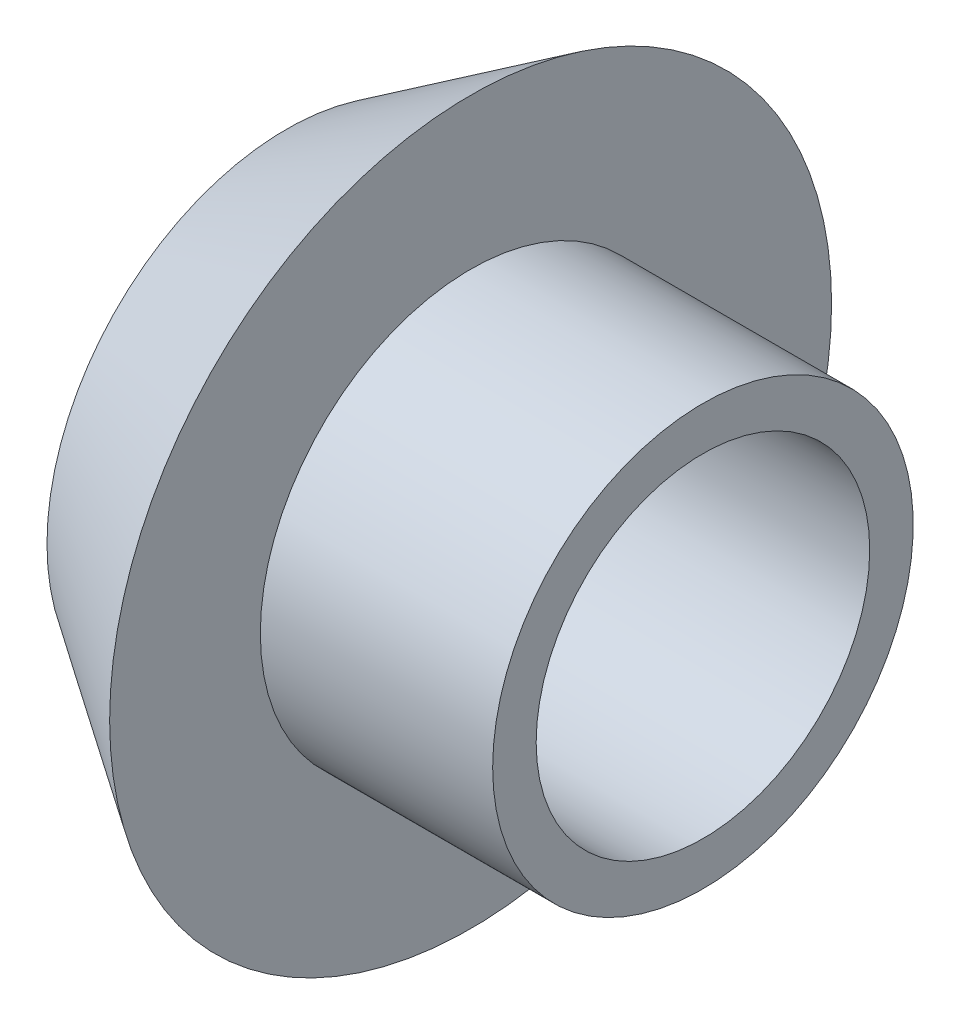
from build123d import *


with BuildPart() as part:
    # Sketch3 → Revolve1 (revolve)
    with BuildSketch(Plane.XY):
        Polygon((-14.36, 16.51), (-1.66, 24.89), (-1.66, 14.5), (14.36, 14.5), (14.36, 11.5), (-14.36, 11.5), align=None)
    revolve(axis=Axis((-14.36, 0, 0), (1, 0, 0)))


solid = part.part
